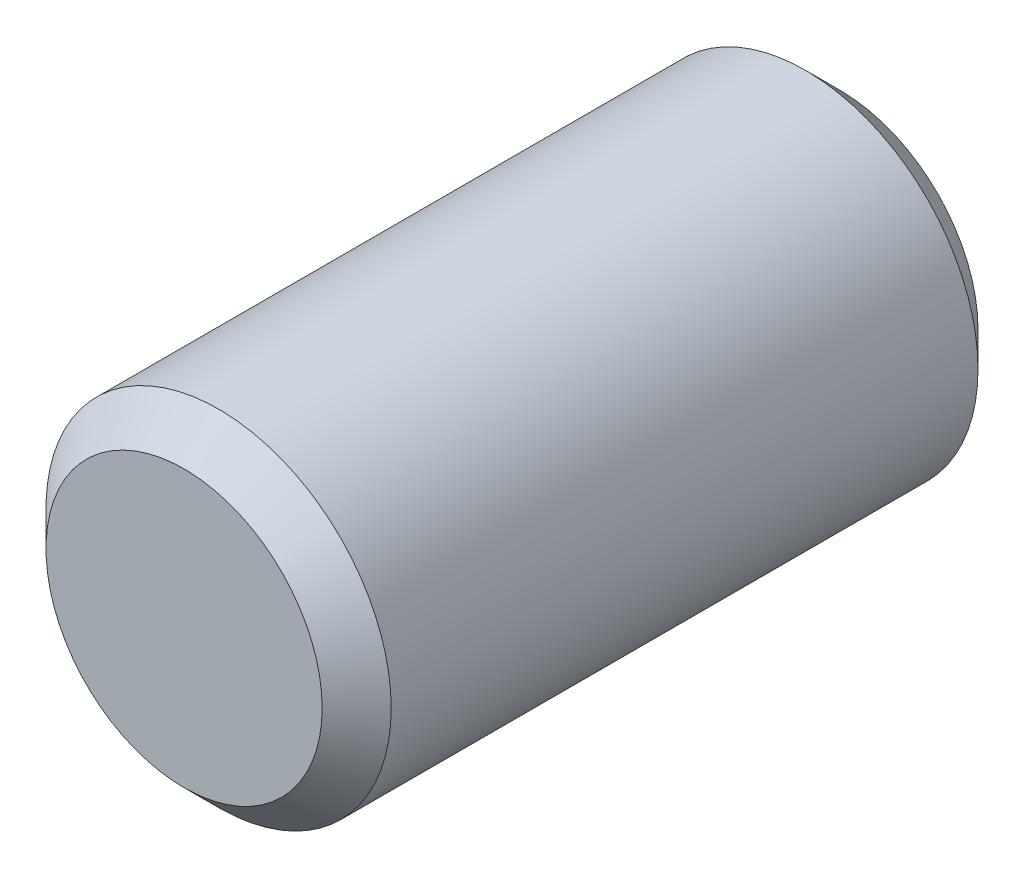
from build123d import *

# Parameters (mm, degrees)
ESQUISSE1_R        = 50
BOSS_EXTRU_1_DEPTH = 190
CHANFREIN2_SIZE    = 10


with BuildPart() as part:
    # Esquisse1 → Boss.-Extru.1 (new body)
    with BuildSketch(Plane.XY):
        Circle(ESQUISSE1_R)
    extrude(amount=BOSS_EXTRU_1_DEPTH)

    # Chanfrein2
    chanfrein2_edges = [part.edges().sort_by_distance(p)[0] for p in [
        (-50, 0, 0),
        (-50, 0, 190),
    ]]
    chamfer(chanfrein2_edges, length=CHANFREIN2_SIZE)


solid = part.part
